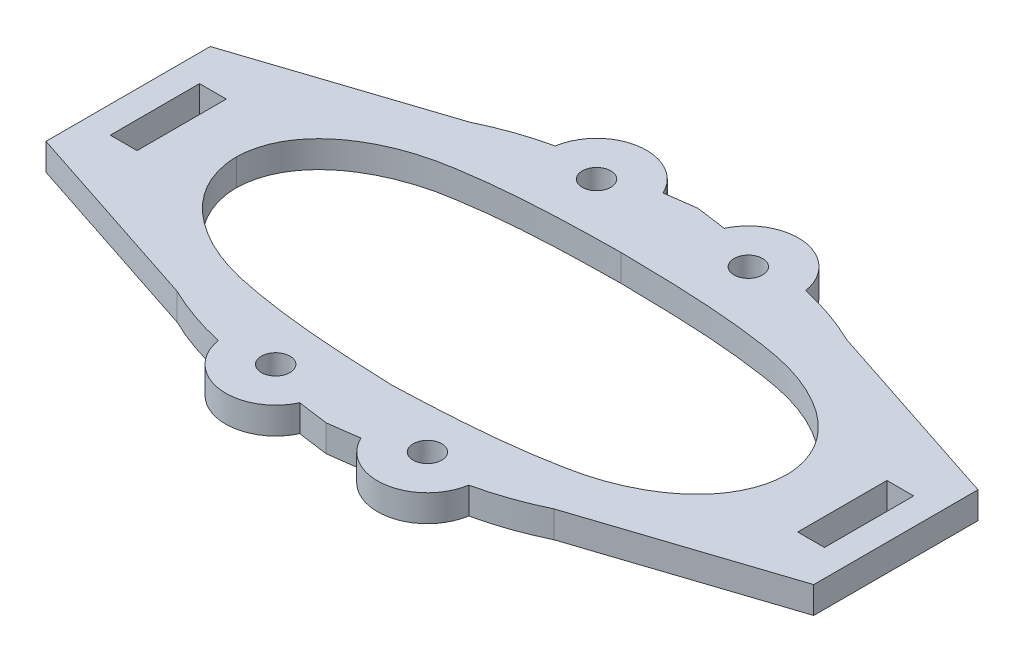
from build123d import *

# Parameters (mm, degrees)
ESBO_O1_R                = 1.6
ESBO_O1_R_2              = 1.600000007
ESBO_O1_W                = 3
ESBO_O1_H                = 10
RESSALTO_EXTRUS_O1_DEPTH = 3


with BuildPart() as part:
    # Esboço1 → Ressalto-extrusão1 (new body)
    with BuildSketch(Plane.XZ.offset(-10)):
        with BuildLine():
            Line((42.999999997, -9.199919627), (21.11055054, -16.399388678))
            ThreePointArc((21.11055054, -16.399388678), (17.640967155, -17.841864894), (14.027295524, -18.871488049))
            ThreePointArc((14.027295524, -18.871488049), (9.270943356, -23.518767255), (3.427492506, -20.344783619))
            ThreePointArc((3.427492506, -20.344783619), (1.714787578, -20.587160488), (-3e-09, -20.814335031))
            ThreePointArc((-3e-09, -20.814335031), (-1.714787584, -20.587160488), (-3.427492513, -20.344783619))
            ThreePointArc((-3.427492513, -20.344783619), (-9.270943363, -23.518767255), (-14.02729553, -18.871488049))
            ThreePointArc((-14.02729553, -18.871488049), (-17.640967162, -17.841864894), (-21.110550547, -16.399388678))
            Line((-21.110550547, -16.399388678), (-43.000000003, -9.199919627))
            Line((-43.000000003, -9.199919627), (-43.000000003, 9.199919627))
            Line((-43.000000003, 9.199919627), (-21.111527461, 16.402363453))
            ThreePointArc((-21.111527461, 16.402363453), (-17.64068144, 17.841429998), (-14.027295586, 18.871540329))
            ThreePointArc((-14.027295586, 18.871540329), (-9.270915171, 23.518776829), (-3.427486355, 20.344772827))
            ThreePointArc((-3.427486355, 20.344772827), (-1.714766445, 20.587024324), (-3e-09, 20.814337605))
            ThreePointArc((-3e-09, 20.814337605), (1.714766438, 20.587024324), (3.427486348, 20.344772827))
            ThreePointArc((3.427486348, 20.344772827), (9.270915164, 23.518776829), (14.027295579, 18.871540329))
            ThreePointArc((14.027295579, 18.871540329), (17.640681433, 17.841429998), (21.111527454, 16.402363453))
            Line((21.111527454, 16.402363453), (42.999999997, 9.199919627))
            Line((42.999999997, 9.199919627), (42.999999997, -9.199919627))
        make_face()
        with Locations((-8.499996016, -17.972093401)):
            Circle(ESBO_O1_R, mode=Mode.SUBTRACT)
        with Locations((-8.500000045, 17.972094091)):
            Circle(ESBO_O1_R_2, mode=Mode.SUBTRACT)
        with Locations((8.500000038, 17.972094091)):
            Circle(ESBO_O1_R_2, mode=Mode.SUBTRACT)
        with Locations((8.499996009, -17.972093401)):
            Circle(ESBO_O1_R, mode=Mode.SUBTRACT)
        with Locations((-38.500000003, 0)):
            Rectangle(ESBO_O1_W, ESBO_O1_H, mode=Mode.SUBTRACT)
        with Locations((38.499999997, 0)):
            Rectangle(ESBO_O1_W, ESBO_O1_H, mode=Mode.SUBTRACT)
        with BuildLine():
            add(Edge.make_bspline(
                [(0, 13.48175396), (-6.225840887, 13.243866192), (-12.481673421, 12.925170728), (-24.656030895, 10.319444852), (-30.737996444, 6.272836714), (-30.833333333, 0)],
                knots=[0, 0, 0, 0, 0.5, 0.5, 1, 1, 1, 1], degree=3))
            add(Edge.make_bspline(
                [(-30.833333333, 0), (-30.664662625, -6.169349261), (-24.406493372, -9.849880174), (-12.309360845, -12.002886564), (-6.143049468, -12.144365954), (-7e-09, -12.225)],
                knots=[0, 0, 0, 0, 0.5, 0.5, 1, 1, 1, 1], degree=3))
            add(Edge.make_bspline(
                [(30.833333326, 0), (30.664662618, -6.169349261), (24.406493365, -9.849880174), (12.309360838, -12.002886564), (6.143049461, -12.144365954), (-7e-09, -12.225)],
                knots=[0, 0, 0, 0, 0.5, 0.5, 1, 1, 1, 1], degree=3))
            add(Edge.make_bspline(
                [(0, 13.48175396), (6.22584088, 13.243866192), (12.481673414, 12.925170728), (24.656030889, 10.319444852), (30.737996437, 6.272836714), (30.833333326, 0)],
                knots=[0, 0, 0, 0, 0.5, 0.5, 1, 1, 1, 1], degree=3))
        make_face(mode=Mode.SUBTRACT)
    extrude(amount=-RESSALTO_EXTRUS_O1_DEPTH)


solid = part.part
